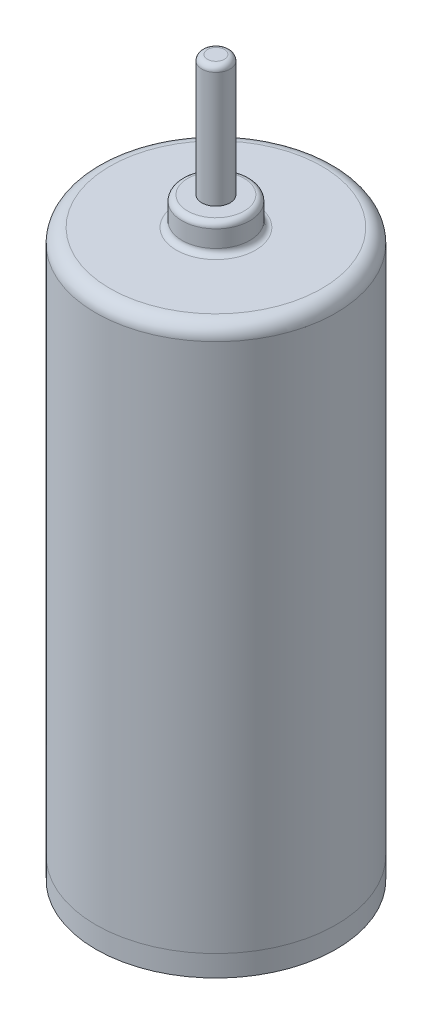
from build123d import *

# Parameters (mm, degrees)
SKETCH1_R           = 4.25
BOSS_EXTRUDE1_DEPTH = 0.75
SKETCH2_R           = 4.25
BOSS_EXTRUDE2_DEPTH = 19.25
SKETCH3_R           = 1.2
BOSS_EXTRUDE3_DEPTH = 1
SKETCH4_R           = 0.5
BOSS_EXTRUDE4_DEPTH = 4.3
FILLET1_R           = 0.5
FILLET2_R           = 0.2
SKETCH5_R           = 0.35
BOSS_EXTRUDE5_DEPTH = 0.25


with BuildPart() as part:
    # Sketch1 → Boss-Extrude1 (new body)
    with BuildSketch(Plane(origin=(0, 0, 0), x_dir=(1, 0, 0), z_dir=(0, 1, 0))):
        Circle(SKETCH1_R)
    extrude(amount=BOSS_EXTRUDE1_DEPTH)

    # Sketch5 → Boss-Extrude5 (add)
    with BuildSketch(Plane.XZ):
        with Locations((-2.25, 0)):
            Circle(SKETCH5_R)
        with Locations((2.25, 0)):
            Circle(SKETCH5_R)
    extrude(amount=BOSS_EXTRUDE5_DEPTH)


with BuildPart() as body_2:
    # Sketch2 → Boss-Extrude2 (new body)
    with BuildSketch(Plane(origin=(0, 0.75, 0), x_dir=(1, 0, 0), z_dir=(0, 1, 0))):
        Circle(SKETCH2_R)
    extrude(amount=BOSS_EXTRUDE2_DEPTH)

    # Sketch3 → Boss-Extrude3 (add)
    with BuildSketch(Plane(origin=(0, 20, 0), x_dir=(1, 0, 0), z_dir=(0, 1, 0))):
        Circle(SKETCH3_R)
    extrude(amount=BOSS_EXTRUDE3_DEPTH)

    # Sketch4 → Boss-Extrude4 (add)
    with BuildSketch(Plane(origin=(0, 21, 0), x_dir=(1, 0, 0), z_dir=(0, 1, 0))):
        Circle(SKETCH4_R)
    extrude(amount=BOSS_EXTRUDE4_DEPTH)

    # Fillet1
    fillet1_edges = [body_2.edges().sort_by_distance(p)[0] for p in [
        (-4.25, 20, 0),
    ]]
    fillet(fillet1_edges, radius=FILLET1_R)

    # Fillet2
    fillet2_edges = [body_2.edges().sort_by_distance(p)[0] for p in [
        (-1.2, 20, 0),
        (-1.2, 21, 0),
        (-0.5, 25.3, 0),
    ]]
    fillet(fillet2_edges, radius=FILLET2_R)


solid = Compound([part.part, body_2.part])
